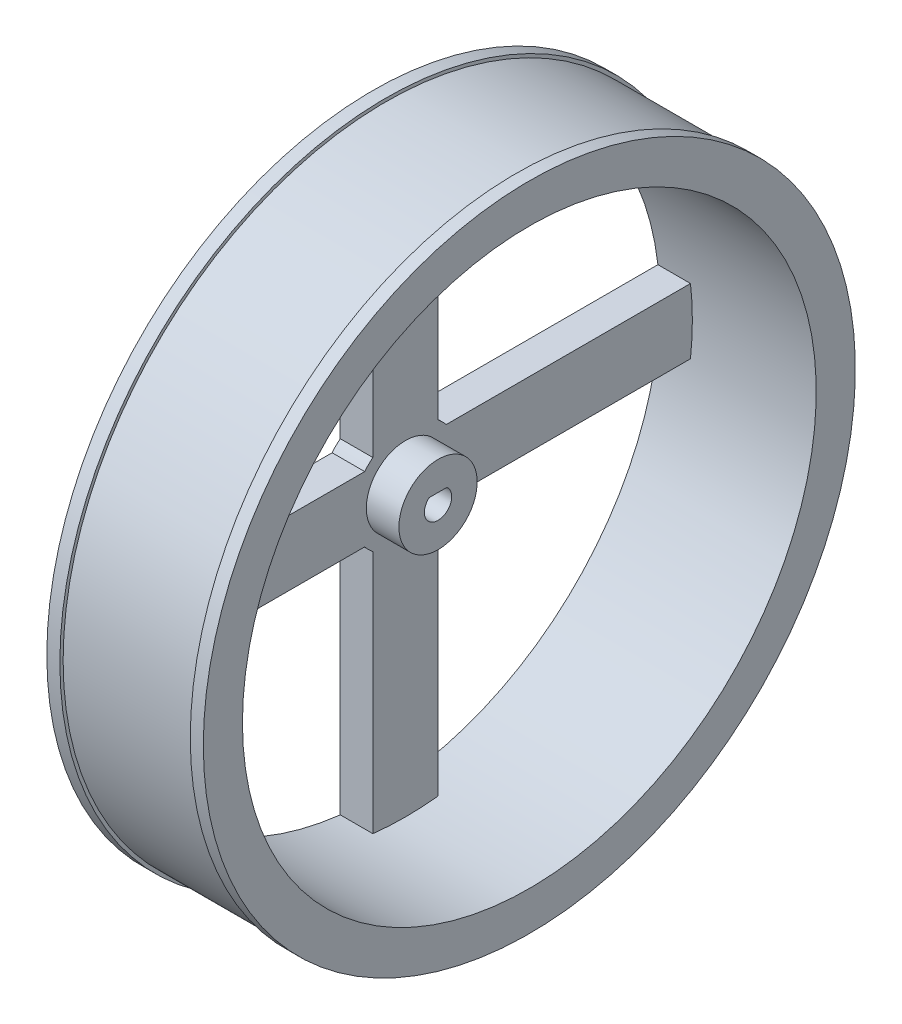
from build123d import *

# Parameters (mm, degrees)
SKETCH1_W               = 10
SKETCH1_H               = 6
SKETCH2_R               = 6
BOSS_EXTRUDE1_DEPTH     = 5
CUT_EXTRUDE1_DEPTH      = 15
CUT_EXTRUDE1_DEPTH_BACK = 11
CIRPATTERN1_COUNT       = 4


with BuildPart() as part:
    # Sketch1 → Revolve1 (revolve)
    with BuildSketch(Plane.XY):
        Polygon((-12, 50), (-12, 44), (12, 44), (12, 50), (10, 50), (10, 49.5), (-10, 49.5), (-10, 50), align=None)
        with Locations((-7, 3)):
            Rectangle(SKETCH1_W, SKETCH1_H)
    revolve(axis=Axis((0, 0, 0), (1, 0, 0)))

    # Sketch2 → Boss-Extrude1 (add)
    with BuildSketch(Plane(origin=(-12, 0, 0), x_dir=(0, 0, -1), z_dir=(1, 0, 0))):
        with BuildLine():
            Line((-5, 6.244997998), (-5, 43.714985989))
            ThreePointArc((-5, 43.714985989), (0, 44), (5, 43.714985989))
            Line((5, 43.714985989), (5, 6.244997998))
            ThreePointArc((5, 6.244997998), (0, -8), (-5, 6.244997998))
        make_face()
        Circle(SKETCH2_R, mode=Mode.SUBTRACT)
    boss_extrude1 = extrude(amount=BOSS_EXTRUDE1_DEPTH)

    # Sketch3 → Cut-Extrude1 (cut, two sides)
    with BuildSketch(Plane(origin=(-2, 0, 0), x_dir=(0, 0, -1), z_dir=(1, 0, 0))) as cut_extrude1_sk:
        with BuildLine():
            Line((-1.360147051, 1.6), (1.360147051, 1.6))
            ThreePointArc((1.360147051, 1.6), (0, -2.1), (-1.360147051, 1.6))
        make_face()
    extrude(amount=CUT_EXTRUDE1_DEPTH, mode=Mode.SUBTRACT)
    extrude(cut_extrude1_sk.sketch, amount=-CUT_EXTRUDE1_DEPTH_BACK, mode=Mode.SUBTRACT)

    # CirPattern1: Boss-Extrude1 ×4 about axis
    cirpattern1_axis = Axis((0, 0, 0), (1, 0, 0))
    for i in range(1, CIRPATTERN1_COUNT):
        add(boss_extrude1.rotate(cirpattern1_axis, i * 360 / CIRPATTERN1_COUNT))


solid = part.part
